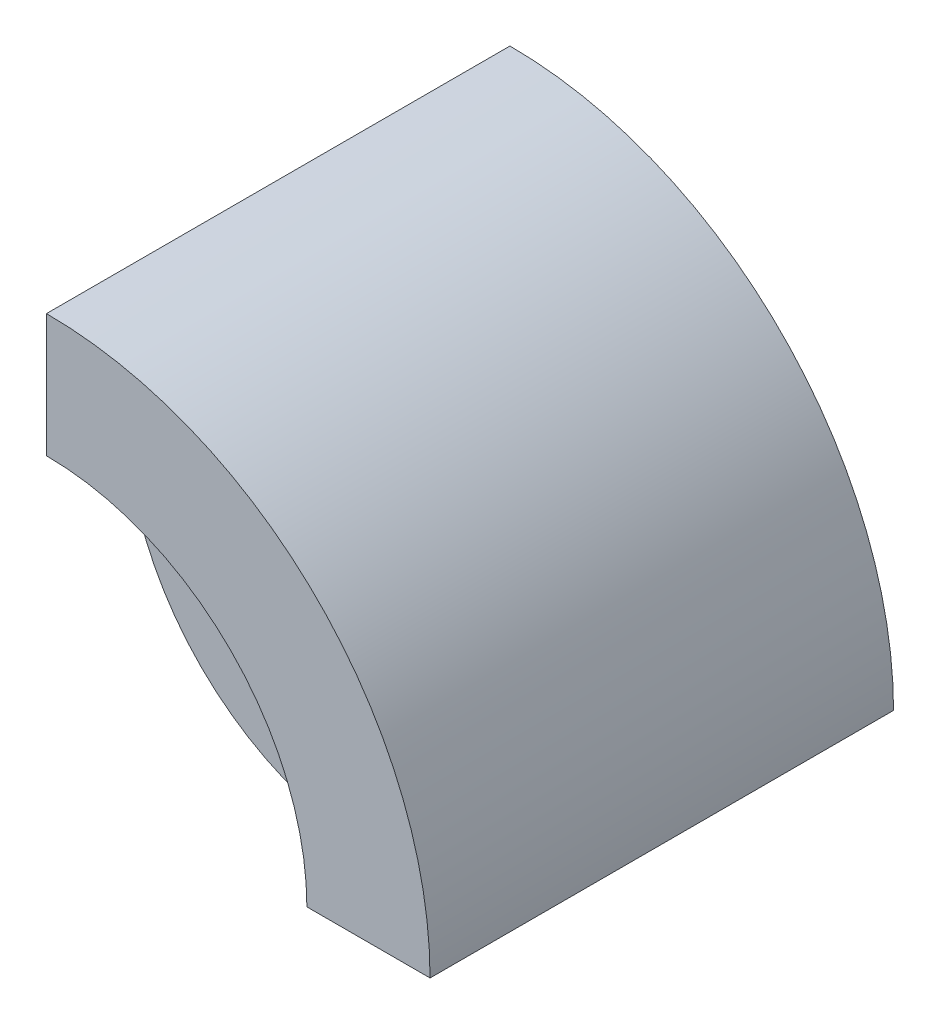
from build123d import *

# Parameters (mm, degrees)
SKETCH1_R           = 11.1
BOSS_EXTRUDE5_DEPTH = 9.525
LEFT_SIDE_DEPTH     = 25


with BuildPart() as part:
    # Sketch1 → Boss-Extrude5 (new body)
    with BuildSketch(Plane.XY):
        with BuildLine():
            ThreePointArc((28.575, 0), (20.205576272, 20.205576272), (0, 28.575))
            Line((0, 28.575), (0, 19.051378432))
            ThreePointArc((0, 19.051378432), (-13.47135888, -13.47135888), (19.051378432, 0))
            Line((19.051378432, 0), (28.575, 0))
        make_face()
        with Locations(Location((0, 0, 0), (0, 0, 180))):
            Circle(SKETCH1_R, mode=Mode.SUBTRACT)
    extrude(amount=BOSS_EXTRUDE5_DEPTH)

    # Sketch3 → Left Side (add)
    with BuildSketch(Plane.XY.offset(9.525)):
        with BuildLine():
            Line((19.4, 0), (28.575, 0))
            ThreePointArc((28.575, 0), (20.205576272, 20.205576272), (0, 28.575))
            Line((0, 28.575), (0, 19.4))
            ThreePointArc((0, 19.4), (13.717871555, 13.717871555), (19.4, 0))
        make_face()
    extrude(amount=LEFT_SIDE_DEPTH)


solid = part.part
